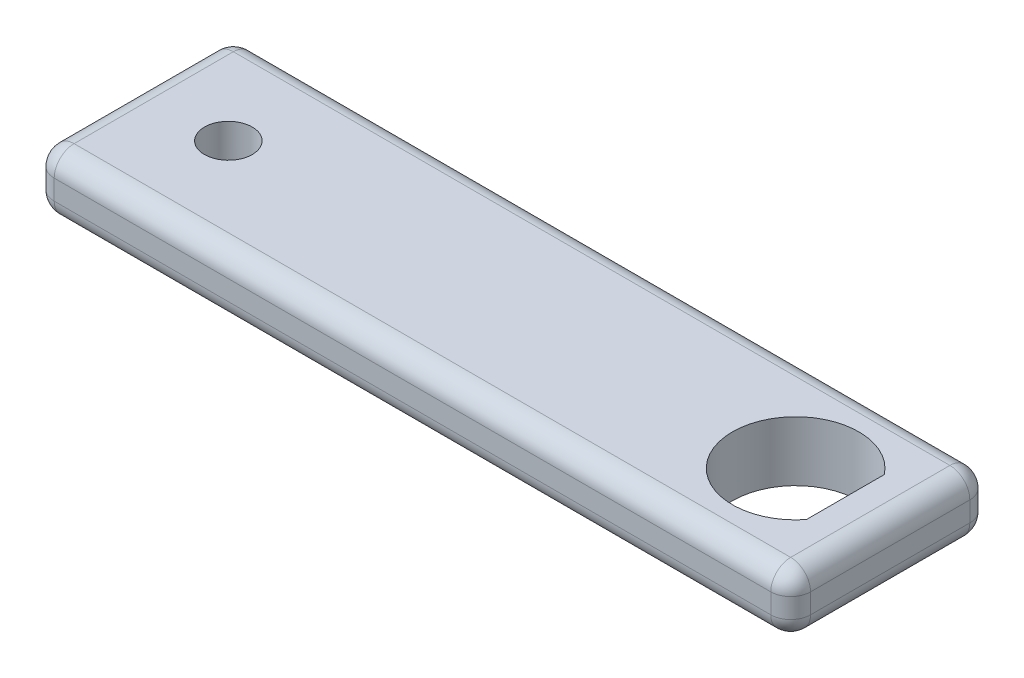
from build123d import *

# Parameters (mm, degrees)
SKETCH1_W           = 76
SKETCH1_H           = 20
BOSS_EXTRUDE1_DEPTH = 6
SKETCH2_R           = 2.4
CUT_EXTRUDE1_DEPTH  = 6
FILLET1_R           = 2


with BuildPart() as part:
    # Sketch1 → Boss-Extrude1 (new body)
    with BuildSketch(Plane(origin=(0, 0, 0), x_dir=(1, 0, 0), z_dir=(0, 1, 0))):
        with Locations((38, 10)):
            Rectangle(SKETCH1_W, SKETCH1_H)
    extrude(amount=BOSS_EXTRUDE1_DEPTH)

    # Sketch2 → Cut-Extrude1 (cut)
    with BuildSketch(Plane(origin=(0, 6, 0), x_dir=(1, 0, 0), z_dir=(0, 1, 0))):
        with Locations((9.5, 10)):
            Circle(SKETCH2_R)
        with BuildLine():
            Line((71.5, 13.914396505), (71.5, 6.085603495))
            ThreePointArc((71.5, 6.085603495), (60.15, 10), (71.5, 13.914396505))
        make_face()
    extrude(amount=-CUT_EXTRUDE1_DEPTH, mode=Mode.SUBTRACT)

    # Fillet1
    fillet1_edges = [part.edges().sort_by_distance(p)[0] for p in [
        (76, 6, -10),
        (38, 6, -20),
        (0, 6, -10),
        (38, 0, -20),
        (76, 0, -10),
        (38, 0, 0),
        (0, 0, -10),
        (38, 6, 0),
        (0, 3, -20),
        (76, 3, -20),
        (76, 3, 0),
        (0, 3, 0),
    ]]
    fillet(fillet1_edges, radius=FILLET1_R)


solid = part.part
